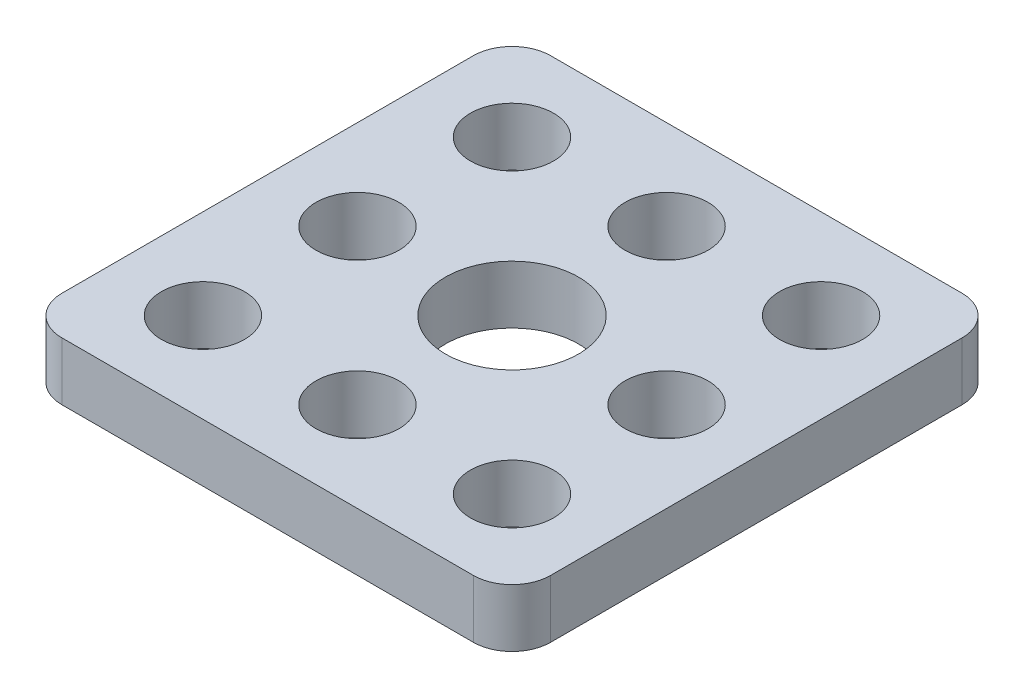
from build123d import *

# Parameters (mm, degrees)
SKETCH1_W           = 25.3
SKETCH1_H           = 25.3
SKETCH1_R           = 2.15
SKETCH1_R_2         = 3.45
BOSS_EXTRUDE1_DEPTH = 3
FILLET1_R           = 2


with BuildPart() as part:
    # Sketch1 → Boss-Extrude1 (new body)
    with BuildSketch(Plane(origin=(0, 0, 0), x_dir=(1, 0, 0), z_dir=(0, 1, 0))):
        with Locations((12.65, 12.65)):
            Rectangle(SKETCH1_W, SKETCH1_H)
        with Locations((4.65, 4.65)):
            Circle(SKETCH1_R, mode=Mode.SUBTRACT)
        with Locations((12.65, 4.65)):
            Circle(SKETCH1_R, mode=Mode.SUBTRACT)
        with Locations((20.65, 4.65)):
            Circle(SKETCH1_R, mode=Mode.SUBTRACT)
        with Locations((4.65, 12.65)):
            Circle(SKETCH1_R, mode=Mode.SUBTRACT)
        with Locations((4.65, 20.65)):
            Circle(SKETCH1_R, mode=Mode.SUBTRACT)
        with Locations((20.65, 12.65)):
            Circle(SKETCH1_R, mode=Mode.SUBTRACT)
        with Locations((20.65, 20.65)):
            Circle(SKETCH1_R, mode=Mode.SUBTRACT)
        with Locations((12.65, 20.65)):
            Circle(SKETCH1_R, mode=Mode.SUBTRACT)
        with Locations((12.65, 12.65)):
            Circle(SKETCH1_R_2, mode=Mode.SUBTRACT)
    extrude(amount=BOSS_EXTRUDE1_DEPTH)

    # Fillet1
    fillet1_edges = [part.edges().sort_by_distance(p)[0] for p in [
        (0, 1.5, -25.3),
        (25.3, 1.5, -25.3),
        (25.3, 1.5, 0),
        (0, 1.5, 0),
    ]]
    fillet(fillet1_edges, radius=FILLET1_R)


solid = part.part
